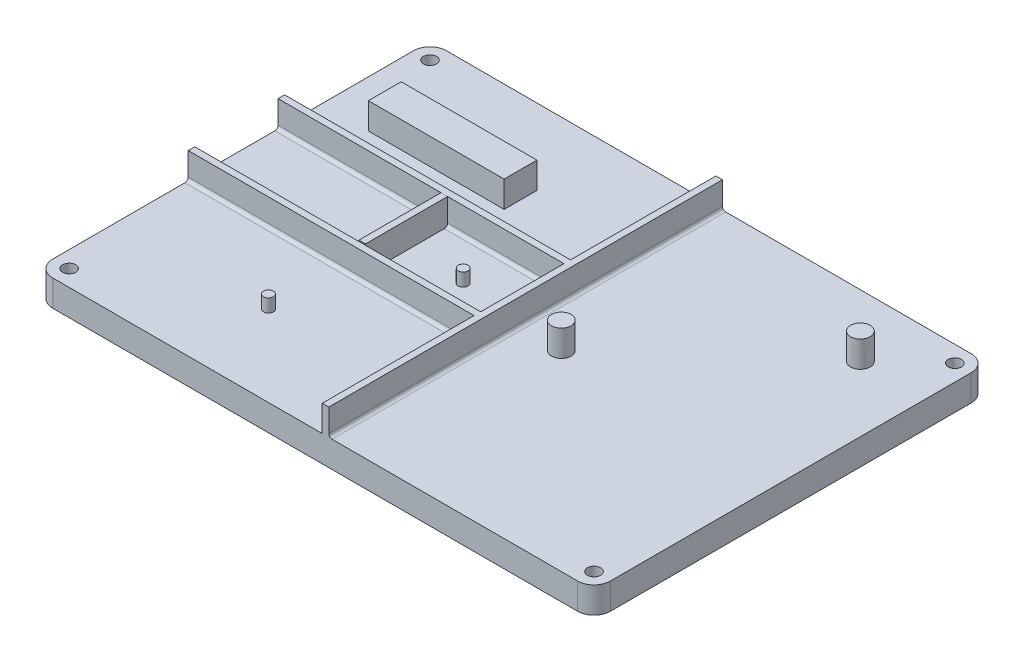
from build123d import *

# Parameters (mm, degrees)
SKETCH1_W            = 170
SKETCH1_H            = 120
BOSS_EXTRUDE1_DEPTH  = 8
SKETCH2_W            = 41.380626675
SKETCH2_H            = 10
BOSS_EXTRUDE2_DEPTH  = 8
SKETCH3_R            = 2
CUT_EXTRUDE1_DEPTH   = 8
SKETCH7_R            = 3
BOSS_EXTRUDE3_DEPTH  = 8
SKETCH8_R            = 1.5
BOSS_EXTRUDE6_DEPTH  = 4
SKETCH9_R            = 1.5
BOSS_EXTRUDE7_DEPTH  = 4
SKETCH10_R           = 3
BOSS_EXTRUDE8_DEPTH  = 8
SKETCH11_W           = 2
SKETCH11_H           = 120
BOSS_EXTRUDE9_DEPTH  = 8
SKETCH13_W           = 87.148503305
SKETCH13_H           = 2
BOSS_EXTRUDE10_DEPTH = 8
BOSS_EXTRUDE11_START = -1.289738394
SKETCH7_3_R          = 3
BOSS_EXTRUDE11_DEPTH = 1.289738394
SKETCH14_W           = 2
SKETCH14_H           = 25
BOSS_EXTRUDE13_DEPTH = 8
SKETCH18_W           = 87.148503305
SKETCH18_H           = 2
BOSS_EXTRUDE16_DEPTH = 8
SKETCH19_R           = 1.5
BOSS_EXTRUDE17_DEPTH = 4
FILLET1_R            = 1
FILLET6_R            = 5


with BuildPart() as part:
    # Sketch1 → Boss-Extrude1 (new body)
    with BuildSketch(Plane(origin=(0, 0, 0), x_dir=(1, 0, 0), z_dir=(0, 1, 0))):
        Rectangle(SKETCH1_W, SKETCH1_H)
    extrude(amount=BOSS_EXTRUDE1_DEPTH)

    # Sketch2 → Boss-Extrude2 (add)
    with BuildSketch(Plane(origin=(-17.791513114, 8, -3.068036611), x_dir=(1, 0, 0), z_dir=(0, 1, 0))):
        with Locations((-32.208486886, 28.840032215)):
            Rectangle(SKETCH2_W, SKETCH2_H)
    extrude(amount=BOSS_EXTRUDE2_DEPTH)

    # Sketch3 → Cut-Extrude1 (cut)
    with BuildSketch(Plane(origin=(0, 8, 0), x_dir=(1, 0, 0), z_dir=(0, 1, 0))):
        with Locations((-80, 55)):
            Circle(SKETCH3_R)
        with Locations((-80, -55)):
            Circle(SKETCH3_R)
        with Locations((80, 55)):
            Circle(SKETCH3_R)
        with Locations((80, -55)):
            Circle(SKETCH3_R)
    extrude(amount=-CUT_EXTRUDE1_DEPTH, mode=Mode.SUBTRACT)

    # Sketch7 → Boss-Extrude3 (add)
    with BuildSketch(Plane(origin=(12.703147983, 8, 3.565766466), x_dir=(1, 0, 0), z_dir=(0, 1, 0))):
        with Locations((52.400485428, 44.659504627)):
            Circle(SKETCH7_R)
    extrude(amount=BOSS_EXTRUDE3_DEPTH)

    # Sketch8 → Boss-Extrude6 (add)
    with BuildSketch(Plane(origin=(0, 16, 3.565766466), x_dir=(1, 0, 0), z_dir=(0, 1, 0))):
        with Locations((65.103633411, 44.659504627)):
            Circle(SKETCH8_R)
    extrude(amount=-BOSS_EXTRUDE6_DEPTH)

    # Sketch9 → Boss-Extrude7 (add)
    with BuildSketch(Plane(origin=(0, 16, 3.565766466), x_dir=(1, 0, 0), z_dir=(0, 1, 0))):
        with Locations((64.905146724, 44.273718651)):
            Circle(SKETCH9_R)
    extrude(amount=-BOSS_EXTRUDE7_DEPTH)

    # Sketch10 → Boss-Extrude8 (add)
    with BuildSketch(Plane(origin=(-8.754663217, 8, 20.46794397), x_dir=(1, 0, 0), z_dir=(0, 1, 0))):
        with Locations((25.406295965, 18.856235287)):
            Circle(SKETCH10_R)
    extrude(amount=BOSS_EXTRUDE8_DEPTH)

    # Sketch11 → Boss-Extrude9 (add)
    with BuildSketch(Plane(origin=(4.148503305, 8, 0), x_dir=(1, 0, 0), z_dir=(0, 1, 0))):
        with Locations((-1, 0)):
            Rectangle(SKETCH11_W, SKETCH11_H)
    extrude(amount=BOSS_EXTRUDE9_DEPTH)

    # Sketch13 → Boss-Extrude10 (add)
    with BuildSketch(Plane(origin=(0, 8, 0), x_dir=(1, 0, 0), z_dir=(0, 1, 0))):
        with Locations((-41.425748347, 14.695581419)):
            Rectangle(SKETCH13_W, SKETCH13_H)
    extrude(amount=BOSS_EXTRUDE10_DEPTH)

    # Sketch7_3 → Boss-Extrude11 (add)
    with BuildSketch(Plane(origin=(12.703147983, 8, 3.565766466), x_dir=(1, 0, 0), z_dir=(0, 1, 0)).offset(BOSS_EXTRUDE11_START)):
        with Locations((52.400485428, 44.659504627)):
            Circle(SKETCH7_3_R)
    extrude(amount=BOSS_EXTRUDE11_DEPTH)

    # Sketch18 → Boss-Extrude16 (add)
    with BuildSketch(Plane(origin=(0, 8, 0), x_dir=(1, 0, 0), z_dir=(0, 1, 0))):
        with Locations((-41.425748347, -12.710714547)):
            Rectangle(SKETCH18_W, SKETCH18_H)
    extrude(amount=BOSS_EXTRUDE16_DEPTH)

    # Sketch19 → Boss-Extrude17 (add)
    with BuildSketch(Plane(origin=(0, 8, 0), x_dir=(1, 0, 0), z_dir=(0, 1, 0))):
        with Locations((-16.06228854, 1.18486687)):
            Circle(SKETCH19_R)
        with Locations((-38.901806458, -35.330630327)):
            Circle(SKETCH19_R)
    extrude(amount=BOSS_EXTRUDE17_DEPTH)

    # Fillet1
    fillet1_edges = [part.edges().sort_by_distance(p)[0] for p in [
        (-41.425748348, 8, 13.710714547),
        (-41.425748348, 8, 11.710714547),
        (-41.425748348, 8, -13.695581419),
        (2.148503305, 8, -0.992433436),
        (4.148503305, 8, 0),
        (2.148503305, 8, -37.847790709),
        (-41.425748348, 8, -15.695581419),
    ]]
    fillet(fillet1_edges, radius=FILLET1_R)

    # Fillet6
    fillet6_edges = [part.edges().sort_by_distance(p)[0] for p in [
        (85, 4, -60),
        (85, 4, 60),
        (-85, 4, 60),
        (-85, 4, -60),
    ]]
    fillet(fillet6_edges, radius=FILLET6_R)


with BuildPart() as body_2:
    # Sketch14 → Boss-Extrude13 (new body)
    with BuildSketch(Plane(origin=(0, 16, 0), x_dir=(1, 0, 0), z_dir=(0, 1, 0))):
        with Locations((-34.330630327, 1.195581419)):
            Rectangle(SKETCH14_W, SKETCH14_H)
    extrude(amount=-BOSS_EXTRUDE13_DEPTH)


solid = Compound([part.part, body_2.part])
